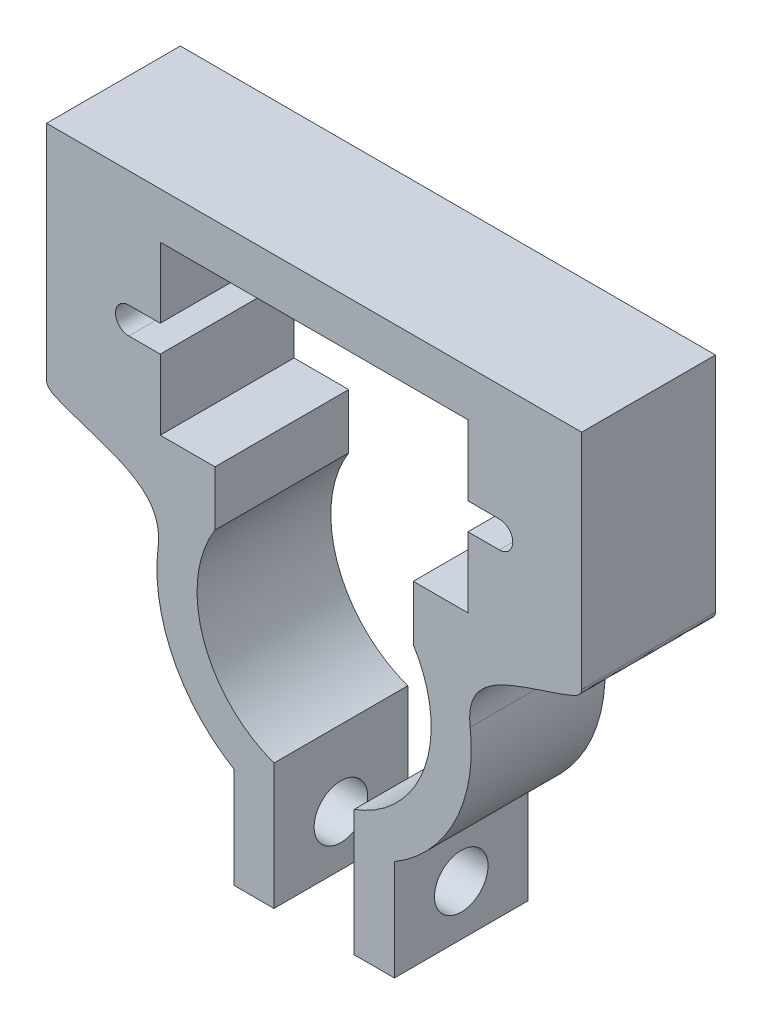
from build123d import *

# Parameters (mm, degrees)
SALIENTE_EXTRUIR1_DEPTH = 10
CROQUIS2_R              = 2
CORTAR_EXTRUIR1_DEPTH   = 27.0000001


with BuildPart() as part:
    # Croquis1 → Saliente-Extruir1 (new body)
    with BuildSketch(Plane.XY):
        with BuildLine():
            Line((11.5, 21.25), (-11.5, 21.25))
            Line((-11.5, 21.25), (-11.5, 16))
            Line((-11.5, 16), (-13.85, 16))
            ThreePointArc((-13.85, 16), (-14.85, 15), (-13.85, 14))
            Line((-13.85, 14), (-11.5, 14))
            Line((-11.5, 14), (-11.5, 8.75))
            Line((-11.5, 8.75), (-7.411101784, 8.75))
            Line((-7.411101784, 8.75), (-7.411101784, 4.65167393))
            ThreePointArc((-7.411101784, 4.65167393), (-8.277405862, -2.836732661), (-3, -8.219641111))
            Line((-3, -8.219641111), (-3, -17.636996672))
            Line((-3, -17.636996672), (-6, -17.636996672))
            Line((-6, -17.636996672), (-6, -10.102598676))
            ThreePointArc((-6, -10.102598676), (-10.54690786, -5.179308313), (-11.662797517, 1.428864608))
            add(Edge.make_bspline(
                [(-20, 8.049530511), (-20, 7.583404659), (-15.923516269, 5.846853582), (-11.193272378, 5.261261744), (-11.662797517, 1.428864608)],
                knots=[0, 0, 0, 0, 0.136185615, 1, 1, 1, 1], degree=3))
            Line((-20, 8.049530511), (-20, 24.696862388))
            Line((-20, 24.696862388), (20, 24.696862388))
            Line((20, 24.696862388), (20, 8.049530511))
            add(Edge.make_bspline(
                [(20, 8.049530511), (20, 7.583404659), (15.923516269, 5.846853582), (11.193272378, 5.261261744), (11.662797517, 1.428864608)],
                knots=[0, 0, 0, 0, 0.136185615, 1, 1, 1, 1], degree=3))
            ThreePointArc((11.662797517, 1.428864608), (10.54690786, -5.179308313), (6, -10.102598676))
            Line((6, -10.102598676), (6, -17.636996672))
            Line((6, -17.636996672), (3, -17.636996672))
            Line((3, -17.636996672), (3, -8.219641111))
            ThreePointArc((3, -8.219641111), (8.277405862, -2.836732661), (7.411101784, 4.65167393))
            Line((7.411101784, 4.65167393), (7.411101784, 8.75))
            Line((7.411101784, 8.75), (11.5, 8.75))
            Line((11.5, 8.75), (11.5, 14))
            Line((11.5, 14), (13.85, 14))
            ThreePointArc((13.85, 14), (14.85, 15), (13.85, 16))
            Line((13.85, 16), (11.5, 16))
            Line((11.5, 16), (11.5, 21.25))
        make_face()
    extrude(amount=SALIENTE_EXTRUIR1_DEPTH)

    # Croquis2 → Cortar-Extruir1 (cut, through all)
    with BuildSketch(Plane.ZY.offset(6)):
        with Locations((5, -13.869797674)):
            Circle(CROQUIS2_R)
    extrude(amount=-CORTAR_EXTRUIR1_DEPTH, mode=Mode.SUBTRACT)


solid = part.part
